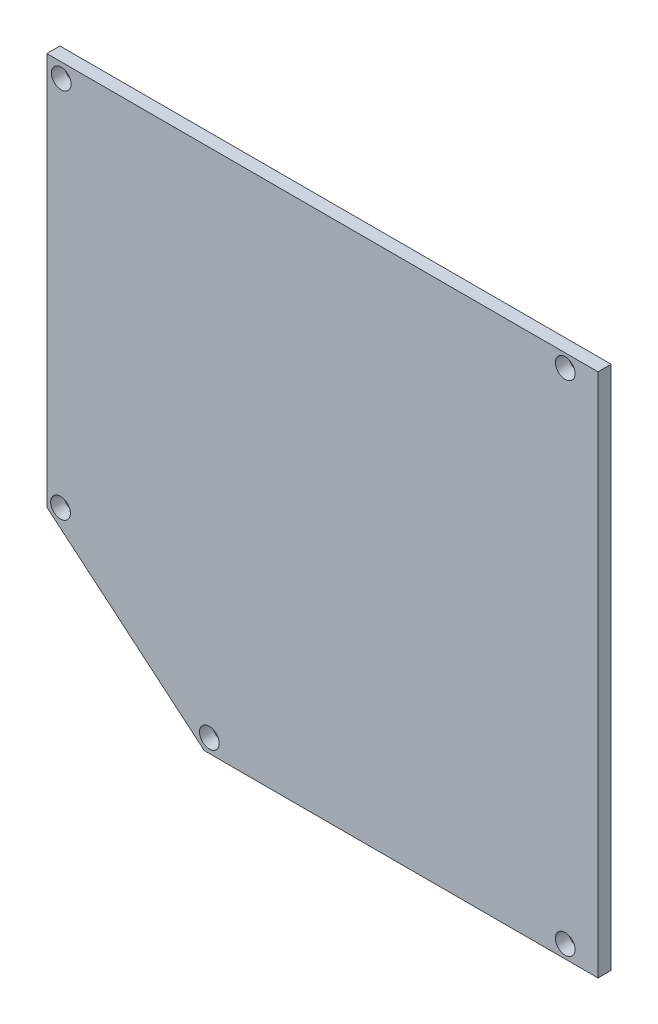
from build123d import *

# Parameters (mm, degrees)
SALIENTE_EXTRUIR1_DEPTH = 2
CROQUIS9_R              = 1.5
CORTAR_EXTRUIR5_DEPTH   = 6


with BuildPart() as part:
    # Croquis1 → Saliente-Extruir1 (new body)
    with BuildSketch(Plane.XY):
        Polygon((0, 0), (60, 0), (60, 80), (-24, 80), (-24, 20.138391148), align=None)
    extrude(amount=SALIENTE_EXTRUIR1_DEPTH)

    # Croquis9 → Cortar-Extruir5 (cut)
    with BuildSketch(Plane.XY.offset(2)):
        with Locations((-21.807968978, 77.807968978)):
            Circle(CROQUIS9_R)
        with Locations((-21.91549209, 21.11041315)):
            Circle(CROQUIS9_R)
        with Locations((0.764337492, 2.1)):
            Circle(CROQUIS9_R)
        with Locations((55, 78)):
            Circle(CROQUIS9_R)
        with Locations((55, 2)):
            Circle(CROQUIS9_R)
    extrude(amount=-CORTAR_EXTRUIR5_DEPTH, mode=Mode.SUBTRACT)


solid = part.part
